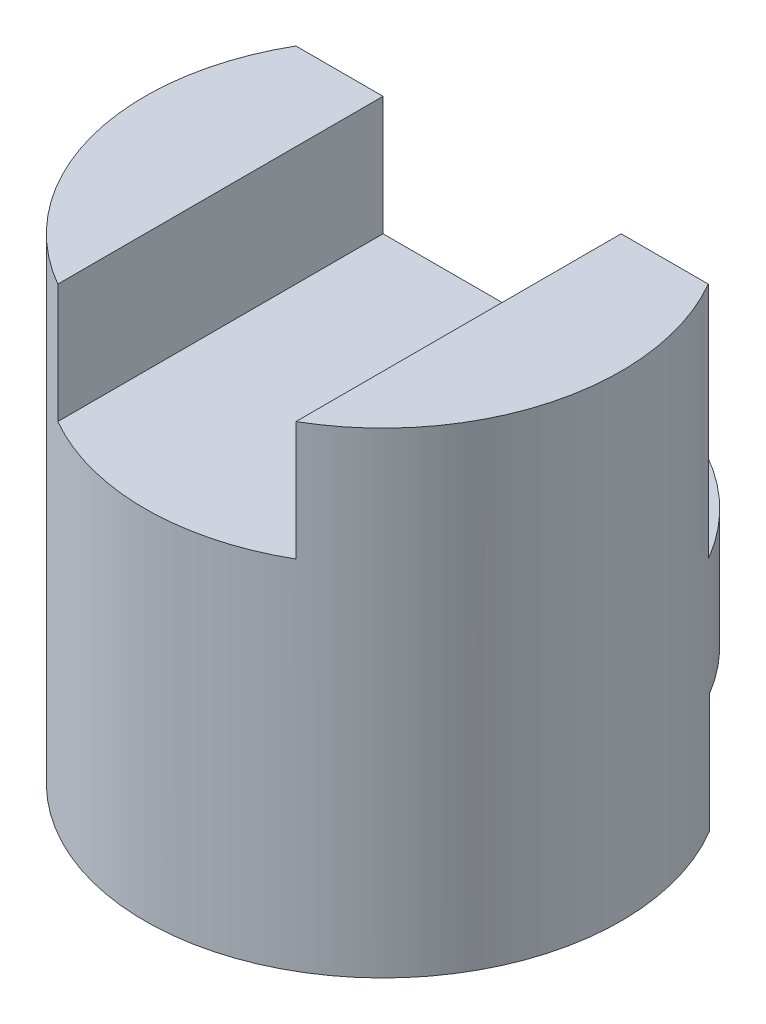
from build123d import *

# Parameters (mm, degrees)
SKETCH1_R           = 2
BOSS_EXTRUDE1_DEPTH = 4
SKETCH2_W           = 2
SKETCH2_H           = 1
CUT_EXTRUDE1_DEPTH  = 5
CUT_EXTRUDE2_DEPTH  = 2
CUT_EXTRUDE3_DEPTH  = 1


with BuildPart() as part:
    # Sketch1 → Boss-Extrude1 (new body)
    with BuildSketch(Plane(origin=(0, 0, 0), x_dir=(1, 0, 0), z_dir=(0, 1, 0))):
        Circle(SKETCH1_R)
    extrude(amount=BOSS_EXTRUDE1_DEPTH)

    # Sketch2 → Cut-Extrude1 (cut, symmetric)
    with BuildSketch(Plane.XY):
        with Locations((0, 3.5)):
            Rectangle(SKETCH2_W, SKETCH2_H)
    extrude(amount=CUT_EXTRUDE1_DEPTH, both=True, mode=Mode.SUBTRACT)

    # Sketch3 → Cut-Extrude2 (cut)
    with BuildSketch(Plane(origin=(0, 4, 0), x_dir=(1, 0, 0), z_dir=(0, 1, 0))):
        with BuildLine():
            Line((-1.732050808, 1), (1.732050808, 1))
            ThreePointArc((1.732050808, 1), (0, 2), (-1.732050808, 1))
        make_face()
    extrude(amount=-CUT_EXTRUDE2_DEPTH, mode=Mode.SUBTRACT)

    # Sketch4 → Cut-Extrude3 (cut)
    with BuildSketch(Plane.XZ):
        with BuildLine():
            Line((1.720168713, -1.020303679), (-1.720168713, -1.020303679))
            ThreePointArc((-1.720168713, -1.020303679), (0, -2.010022353), (1.720168713, -1.020303679))
        make_face()
    extrude(amount=-CUT_EXTRUDE3_DEPTH, mode=Mode.SUBTRACT)


solid = part.part
